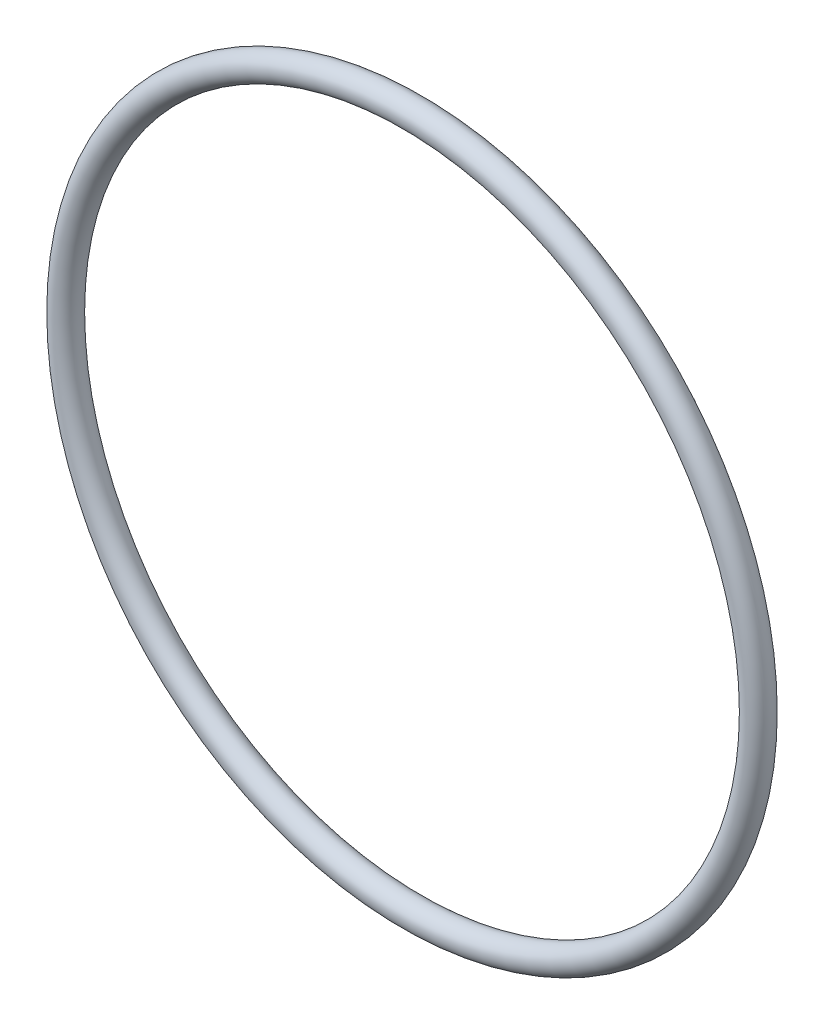
from build123d import *

# Parameters (mm, degrees)
SKETCH1_R = 0.889


with BuildPart() as part:
    # Sketch1 → Revolve1 (revolve)
    with BuildSketch(Plane(origin=(0, 0, 0), x_dir=(0, -1, 0), z_dir=(1, 0, 0))):
        with Locations((22.9743, 0)):
            Circle(SKETCH1_R)
    revolve(axis=Axis((0, 0, 0.889), (0, 0, -1)))


solid = part.part
